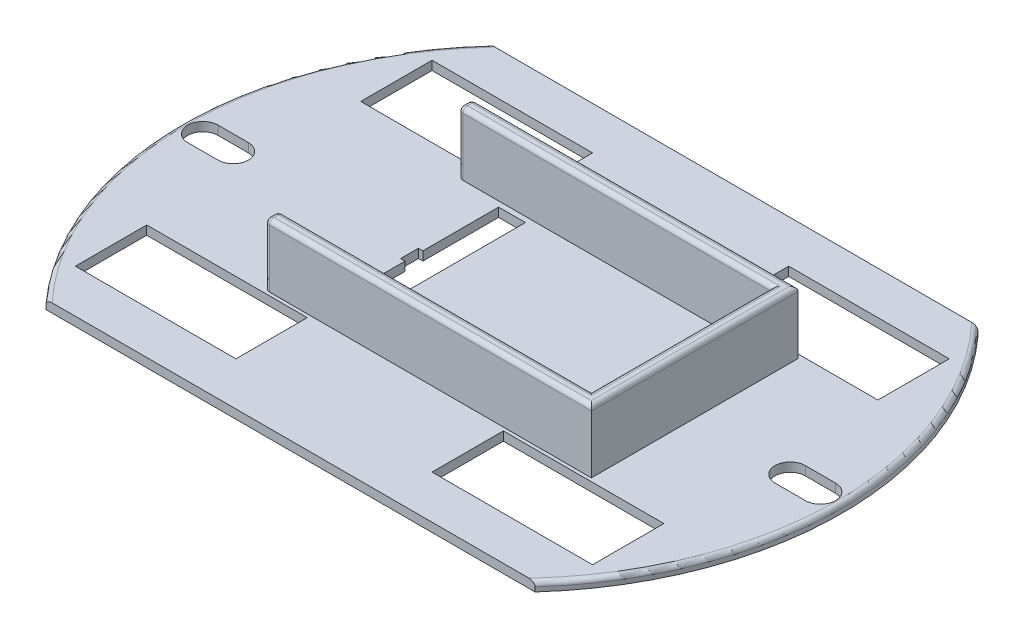
from build123d import *

# Parameters (mm, degrees)
BOSS_EXTRUDE1_DEPTH     = 2
SKETCH2_W               = 3.5
SKETCH2_H               = 2
CUT_EXTRUDE1_DEPTH      = 22
BOSS_EXTRUDE2_DEPTH     = 7
BOSS_EXTRUDE3_DEPTH     = 6
SKETCH5_R               = 2.25
CUT_EXTRUDE3_DEPTH      = 37
CUT_EXTRUDE3_DEPTH_BACK = 37
FILLET1_R               = 3
FILLET2_R               = 0.5
CUT_EXTRUDE4_DEPTH      = 37
FILLET3_R               = 0.5
FILLET4_R               = 0.5
CUT_EXTRUDE5_DEPTH      = 10
FILLET8_R               = 1
SKETCH8_W               = 0.1
SKETCH8_H               = 1
CUT_EXTRUDE6_DEPTH      = 0.1
SKETCH10_R              = 57.556720945
CUT_EXTRUDE7_DEPTH      = 11
CUT_EXTRUDE7_DEPTH_BACK = 1


with BuildPart() as part:
    # Sketch1 → Boss-Extrude1 (new body)
    with BuildSketch(Plane(origin=(0, 0, 0), x_dir=(1, 0, 0), z_dir=(0, 1, 0))):
        with BuildLine():
            Line((-27.424590139, -24.837307739), (27.424590139, -24.837307739))
            ThreePointArc((27.424590139, -24.837307739), (37, 0), (27.424590139, 24.837307739))
            Line((27.424590139, 24.837307739), (-27.424590139, 24.837307739))
            ThreePointArc((-27.424590139, 24.837307739), (-37, 0), (-27.424590139, -24.837307739))
        make_face()
    extrude(amount=BOSS_EXTRUDE1_DEPTH)

    # Sketch2 → Cut-Extrude1 (cut)
    with BuildSketch(Plane.XZ):
        Polygon((-8, 0), (-8, 9.5), (-11, 9.5), (-11, -9.5), (-8, -9.5), align=None)
        with Locations((-9.75, 0)):
            Rectangle(SKETCH2_W, SKETCH2_H)
    extrude(amount=-CUT_EXTRUDE1_DEPTH, mode=Mode.SUBTRACT)

    # Sketch3 → Boss-Extrude2 (add)
    with BuildSketch(Plane(origin=(0, 2, 0), x_dir=(1, 0, 0), z_dir=(0, 1, 0))):
        Polygon((2.9, 11.6), (2.9, 10.1), (19, 10.1), (20.5, 10.1), (20.5, 11.6), align=None)
        Polygon((20.5, 10.1), (19, 10.1), (19, -10.1), (19, -11.6), (20.5, -11.6), align=None)
        Polygon((19, -11.6), (19, -10.1), (-14.6, -10.1), (-16.1, -10.1), (-16.1, -11.6), align=None)
        Polygon((-14.6, 10.1), (2.9, 10.1), (2.9, 11.6), (-16.1, 11.6), (-16.1, 10.1), align=None)
    extrude(amount=BOSS_EXTRUDE2_DEPTH)

    # Sketch4 → Boss-Extrude3 (add)
    with BuildSketch(Plane.XZ):
        Polygon((-8, 0), (-8.02303658, 9.318964787), (-3, 9.318964787), (-3, -9.5), (-8, -9.5), align=None)
    extrude(amount=BOSS_EXTRUDE3_DEPTH)

    # Sketch5 → Cut-Extrude3 (cut, two sides)
    with BuildSketch(Plane.ZY.offset(8)) as cut_extrude3_sk:
        with Locations((-5.031035213, -2.35)):
            Circle(SKETCH5_R)
        with Locations((5.031035213, -2.35)):
            Circle(SKETCH5_R)
    extrude(amount=CUT_EXTRUDE3_DEPTH, mode=Mode.SUBTRACT)
    extrude(cut_extrude3_sk.sketch, amount=-CUT_EXTRUDE3_DEPTH_BACK, mode=Mode.SUBTRACT)

    # Fillet1
    fillet1_edges = [part.edges().sort_by_distance(p)[0] for p in [
        (-5.5, -6, -9.5),
        (-5.51151829, -6, 9.318964787),
    ]]
    fillet(fillet1_edges, radius=FILLET1_R)

    # Fillet2
    fillet2_edges = [part.edges().sort_by_distance(p)[0] for p in [
        (-37, 2, 0),
        (37, 2, 0),
    ]]
    fillet(fillet2_edges, radius=FILLET2_R)

    # Sketch6 → Cut-Extrude4 (cut)
    with BuildSketch(Plane.XZ):
        with BuildLine():
            Line((-34.696885188, 1.668964787), (-31.296885188, 1.668964787))
            ThreePointArc((-31.296885188, 1.668964787), (-29.596885188, -0.031035213), (-31.296885188, -1.731035213))
            Line((-31.296885188, -1.731035213), (-34.696885188, -1.731035213))
            ThreePointArc((-34.696885188, -1.731035213), (-36.396885188, -0.031035213), (-34.696885188, 1.668964787))
        make_face()
        with BuildLine():
            Line((31.302827177, 1.806746588), (34.702827177, 1.806746588))
            ThreePointArc((34.702827177, 1.806746588), (36.402827177, 0.106746588), (34.702827177, -1.593253412))
            Line((34.702827177, -1.593253412), (31.302827177, -1.593253412))
            ThreePointArc((31.302827177, -1.593253412), (29.602827177, 0.106746588), (31.302827177, 1.806746588))
        make_face()
    extrude(amount=-CUT_EXTRUDE4_DEPTH, mode=Mode.SUBTRACT)

    # Fillet3
    fillet3_edges = [part.edges().sort_by_distance(p)[0] for p in [
        (20.5, 9, 0),
        (2.2, 9, -11.6),
        (2.2, 9, 11.6),
        (1.45, 9, -10.1),
        (19, 9, 0),
        (1.45, 9, 10.1),
    ]]
    fillet(fillet3_edges, radius=FILLET3_R)

    # Fillet4
    fillet4_edges = [part.edges().sort_by_distance(p)[0] for p in [
        (-16.1, 9, -10.85),
        (-16.1, 9, 10.85),
        (-16.1, 5.25, -10.1),
        (-16.1, 5.25, -11.6),
        (-16.1, 8.853553391, -11.453553391),
        (-16.1, 8.853553391, -10.246446609),
        (-16.1, 5.25, 11.6),
        (-16.1, 5.25, 10.1),
        (-16.1, 8.853553391, 10.246446609),
        (-16.1, 8.853553391, 11.453553391),
    ]]
    fillet(fillet4_edges, radius=FILLET4_R)

    # Sketch7 → Cut-Extrude5 (cut)
    with BuildSketch(Plane.XZ):
        Polygon((-19.996885188, 19.968964787), (-10.996885188, 19.968964787), (-10.996885188, 11.968964787), (-28.996885188, 11.968964787), (-28.996885188, 19.968964787), align=None)
        Polygon((11.003114812, 11.968964787), (20.003114812, 11.968964787), (20.003114812, 14.968964787), (20.003114812, 19.968964787), (11.003114812, 19.968964787), align=None)
        Polygon((20.003114812, 14.968964787), (20.003114812, 11.968964787), (29.003114812, 11.968964787), (29.003114812, 19.968964787), (20.003114812, 19.968964787), align=None)
        Polygon((-28.996885188, -12.031035213), (-28.996885188, -20.031035213), (-19.996885188, -20.031035213), (-10.996885188, -20.031035213), (-10.996885188, -12.031035213), align=None)
        Polygon((20.003114812, -20.031035213), (11.003114812, -20.031035213), (11.003114812, -12.031035213), (29.003114812, -12.031035213), (29.003114812, -20.031035213), align=None)
    extrude(amount=-CUT_EXTRUDE5_DEPTH, mode=Mode.SUBTRACT)

    # Fillet8
    fillet8_edges = [part.edges().sort_by_distance(p)[0] for p in [
        (11.003114812, 0, 15.968964787),
        (20.003114812, 0, 11.968964787),
        (29.003114812, 0, 15.968964787),
        (20.003114812, 0, 19.968964787),
        (-28.996885188, 0, -16.031035213),
        (-19.996885188, 0, -20.031035213),
        (-10.996885188, 0, -16.031035213),
        (-19.996885188, 0, -12.031035213),
        (20.003114812, 0, -20.031035213),
        (11.003114812, 0, -16.031035213),
        (20.003114812, 0, -12.031035213),
        (29.003114812, 0, -16.031035213),
        (-19.996885188, 0, 19.968964787),
        (-10.996885188, 0, 15.968964787),
        (-19.996885188, 0, 11.968964787),
        (-28.996885188, 0, 15.968964787),
    ]]
    fillet(fillet8_edges, radius=FILLET8_R)

    # Sketch8 → Cut-Extrude6 (cut)
    with BuildSketch(Plane.XY.offset(24.837307739)):
        with Locations((-0.05, 0.5)):
            Rectangle(SKETCH8_W, SKETCH8_H)
        with Locations((0.05, 0.5)):
            Rectangle(SKETCH8_W, SKETCH8_H)
    extrude(amount=-CUT_EXTRUDE6_DEPTH, mode=Mode.SUBTRACT)

    # Sketch10 → Cut-Extrude7 (cut, two sides)
    with BuildSketch(Plane.XZ) as cut_extrude7_sk:
        Circle(SKETCH10_R)
    extrude(amount=CUT_EXTRUDE7_DEPTH, mode=Mode.SUBTRACT)
    extrude(cut_extrude7_sk.sketch, amount=-CUT_EXTRUDE7_DEPTH_BACK, mode=Mode.SUBTRACT)


solid = part.part
